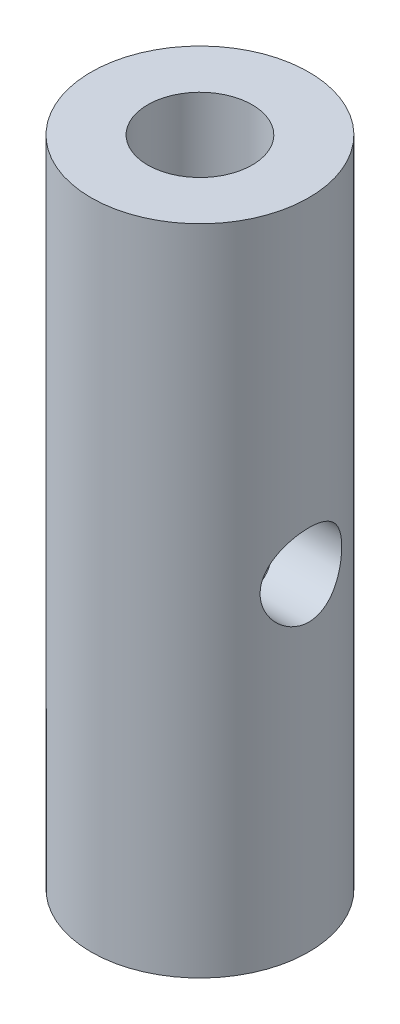
from build123d import *

# Parameters (mm, degrees)
SKETCH1_R                            = 3.175
SKETCH1_R_2                          = 1.5875
BOSS_EXTRUDE1_DEPTH                  = 19.05
TAPPED_HOLE_FOR_4_40_HELICOIL2_D     = 3.048
TAPPED_HOLE_FOR_4_40_HELICOIL2_DEPTH = 9.6012
TAPPED_HOLE_FOR_4_40_HELICOIL2_TIP   = 0.915711583
SKETCH7_W                            = 1.190625
SKETCH7_H                            = 3.175
TAPPED_HOLE_FOR_4_40_HELICOIL3_D     = 3.048
TAPPED_HOLE_FOR_4_40_HELICOIL3_DEPTH = 9.6012
TAPPED_HOLE_FOR_4_40_HELICOIL3_TIP   = 0.915711583


with BuildPart() as part:
    # Sketch1 → Boss-Extrude1 (new body)
    with BuildSketch(Plane(origin=(0, 0, 0), x_dir=(1, 0, 0), z_dir=(0, 1, 0))):
        with Locations(Location((0, 0, 0), (0, 0, 270))):  # turned: the seam where the file's is
            Circle(SKETCH1_R)
        Circle(SKETCH1_R_2, mode=Mode.SUBTRACT)
        Circle(SKETCH1_R_2)
    extrude(amount=BOSS_EXTRUDE1_DEPTH)

    # Tapped Hole for #4-40 Helicoil2
    with Locations(Plane(origin=(0, 19.05, 0), x_dir=(1, 0, 0), z_dir=(0, 1, 0))):
        with Locations((0, 0)):
            Hole(TAPPED_HOLE_FOR_4_40_HELICOIL2_D / 2, depth=TAPPED_HOLE_FOR_4_40_HELICOIL2_DEPTH)
            with Locations((0, 0, -(TAPPED_HOLE_FOR_4_40_HELICOIL2_DEPTH + TAPPED_HOLE_FOR_4_40_HELICOIL2_TIP / 2))):  # 118° drill point
                Cone(0, TAPPED_HOLE_FOR_4_40_HELICOIL2_D / 2, TAPPED_HOLE_FOR_4_40_HELICOIL2_TIP, mode=Mode.SUBTRACT)

    # Sketch7 → 3/32 (0.09375) Diameter Hole1 (revolve, cut)
    with BuildSketch(Plane.ZX.offset(9.525)):
        with Locations((0.5953125, 1.5875)):
            Rectangle(SKETCH7_W, SKETCH7_H)
    revolve(axis=Axis((-6.35, 9.525, 0), (1, 0, 0)), mode=Mode.SUBTRACT)

    # Tapped Hole for #4-40 Helicoil3
    with Locations(Plane(origin=(0, 0, 0), x_dir=(-1, 0, 0), z_dir=(0, -1, 0))):
        with Locations((0, 0)):
            Hole(TAPPED_HOLE_FOR_4_40_HELICOIL3_D / 2, depth=TAPPED_HOLE_FOR_4_40_HELICOIL3_DEPTH)
            with Locations((0, 0, -(TAPPED_HOLE_FOR_4_40_HELICOIL3_DEPTH + TAPPED_HOLE_FOR_4_40_HELICOIL3_TIP / 2))):  # 118° drill point
                Cone(0, TAPPED_HOLE_FOR_4_40_HELICOIL3_D / 2, TAPPED_HOLE_FOR_4_40_HELICOIL3_TIP, mode=Mode.SUBTRACT)


solid = part.part
